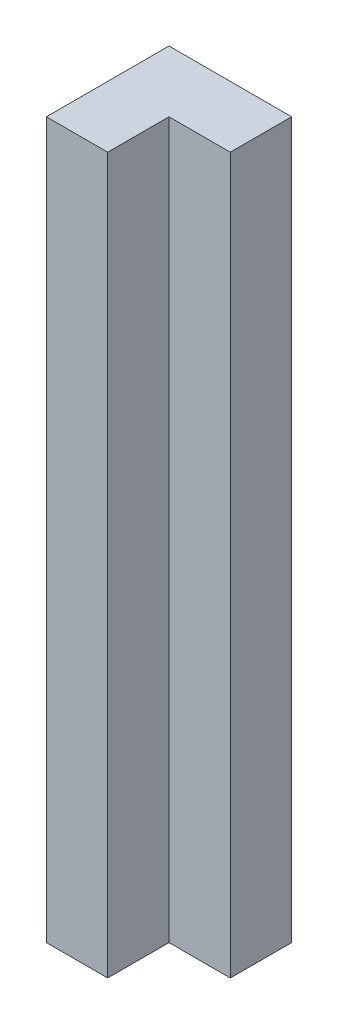
from build123d import *

# Parameters (mm, degrees)
BOSS_EXTRUDE2_DEPTH = 35


with BuildPart() as part:
    # Sketch2 → Boss-Extrude2 (new body)
    with BuildSketch(Plane(origin=(0, 0, 0), x_dir=(1, 0, 0), z_dir=(0, 1, 0))):
        Polygon((0, 0), (0, -6), (3, -6), (3, -3), (6, -3), (6, 0), align=None)
    extrude(amount=BOSS_EXTRUDE2_DEPTH)


solid = part.part
